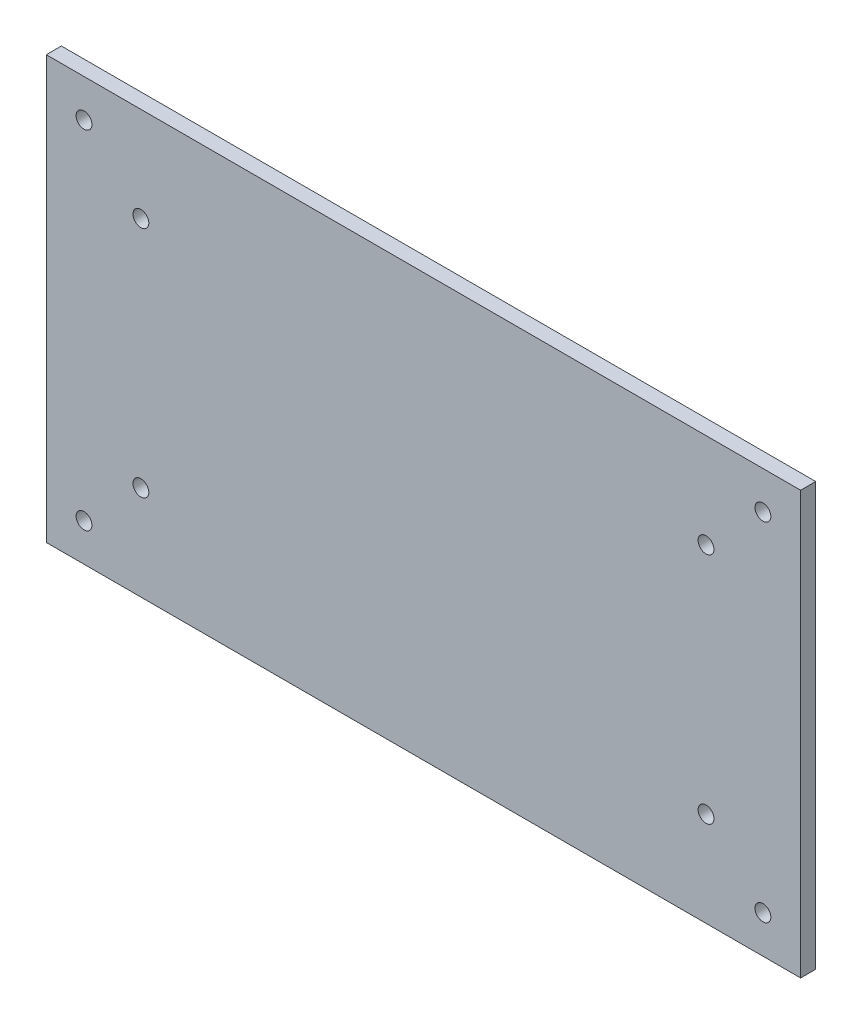
from build123d import *

# Parameters (mm, degrees)
ESQUISSE1_W        = 100
ESQUISSE1_H        = 56
ESQUISSE1_R        = 1.05
BOSS_EXTRU_1_DEPTH = 2


with BuildPart() as part:
    # Esquisse1 → Boss.-Extru.1 (new body)
    with BuildSketch(Plane.XY):
        with Locations((-50.404264154, 144.947419355)):
            Rectangle(ESQUISSE1_W, ESQUISSE1_H)
        with Locations((-5.404264154, 167.947419355)):
            Circle(ESQUISSE1_R, mode=Mode.SUBTRACT)
        with Locations((-95.404264154, 167.947419355)):
            Circle(ESQUISSE1_R, mode=Mode.SUBTRACT)
        with Locations((-95.404264154, 121.947419355)):
            Circle(ESQUISSE1_R, mode=Mode.SUBTRACT)
        with Locations((-5.404264154, 121.947419355)):
            Circle(ESQUISSE1_R, mode=Mode.SUBTRACT)
        with Locations((-12.944264154, 129.487419355)):
            Circle(ESQUISSE1_R, mode=Mode.SUBTRACT)
        with Locations((-12.944264154, 160.407419355)):
            Circle(ESQUISSE1_R, mode=Mode.SUBTRACT)
        with Locations((-87.864264154, 129.487419355)):
            Circle(ESQUISSE1_R, mode=Mode.SUBTRACT)
        with Locations((-87.864264154, 160.407419355)):
            Circle(ESQUISSE1_R, mode=Mode.SUBTRACT)
    extrude(amount=BOSS_EXTRU_1_DEPTH)


solid = part.part
